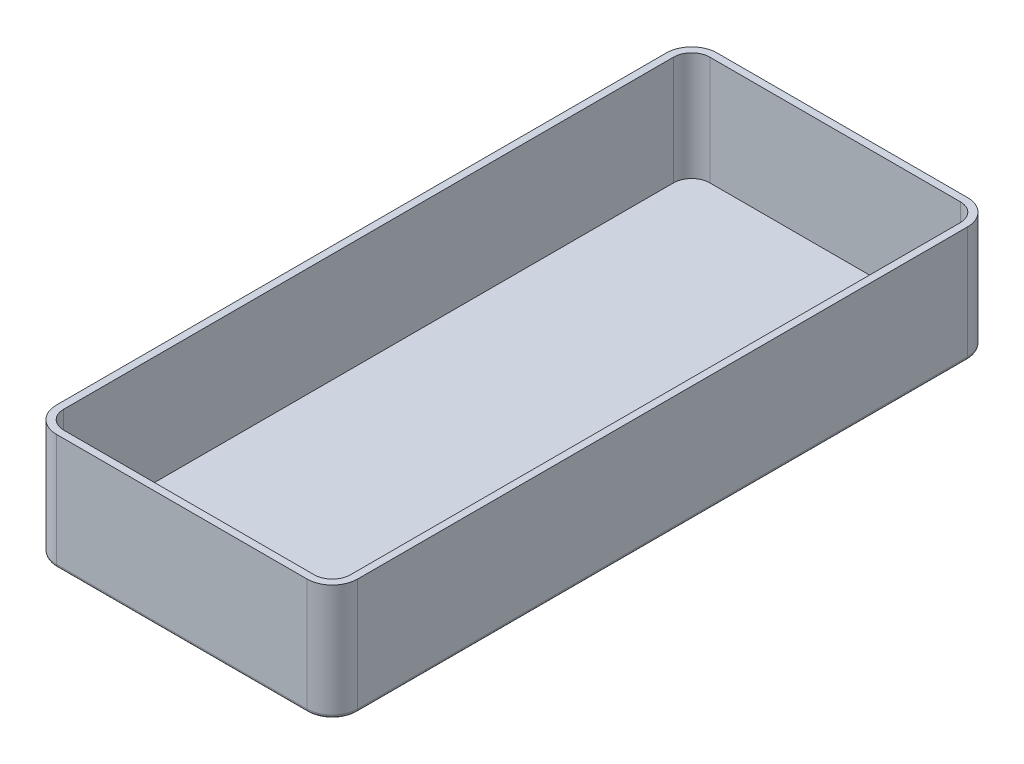
from build123d import *

# Parameters (mm, degrees)
EXTRUDE_1_DEPTH = 32
FILLET_1_R      = 1
SHELL_2_T       = -2


with BuildPart() as part:
    # Эскиз1 → Бобышка-Вытянуть1 (new body)
    with BuildSketch(Plane(origin=(0, 0, 0), x_dir=(1, 0, 0), z_dir=(0, 1, 0))):
        with BuildLine():
            Line((-7, 0), (-76, 0))
            ThreePointArc((-76, 0), (-80.949747468, 2.050252532), (-83, 7))
            Line((-83, 7), (-83, 175))
            ThreePointArc((-83, 175), (-80.949747468, 179.949747468), (-76, 182))
            Line((-76, 182), (-7, 182))
            ThreePointArc((-7, 182), (-2.050252532, 179.949747468), (0, 175))
            Line((0, 175), (0, 7))
            ThreePointArc((0, 7), (-2.050252532, 2.050252532), (-7, 0))
        make_face()
    extrude(amount=EXTRUDE_1_DEPTH)

    # Скругление1
    fillet_1_edges = [part.edges().sort_by_distance(p)[0] for p in [
        (0, 0, -91),
        (-2.050252532, 0, -2.050252532),
        (-41.5, 0, 0),
        (-80.949747468, 0, -2.050252532),
        (-83, 0, -91),
        (-80.949747468, 0, -179.949747468),
        (-41.5, 0, -182),
        (-2.050252532, 0, -179.949747468),
    ]]
    fillet(fillet_1_edges, radius=FILLET_1_R)

    # Оболочка2
    shell_2_openings = [part.faces().sort_by_distance(p)[0] for p in [
        (-41.5, 32, -91),
    ]]
    offset(amount=SHELL_2_T, openings=shell_2_openings, kind=Kind.INTERSECTION)


solid = part.part
